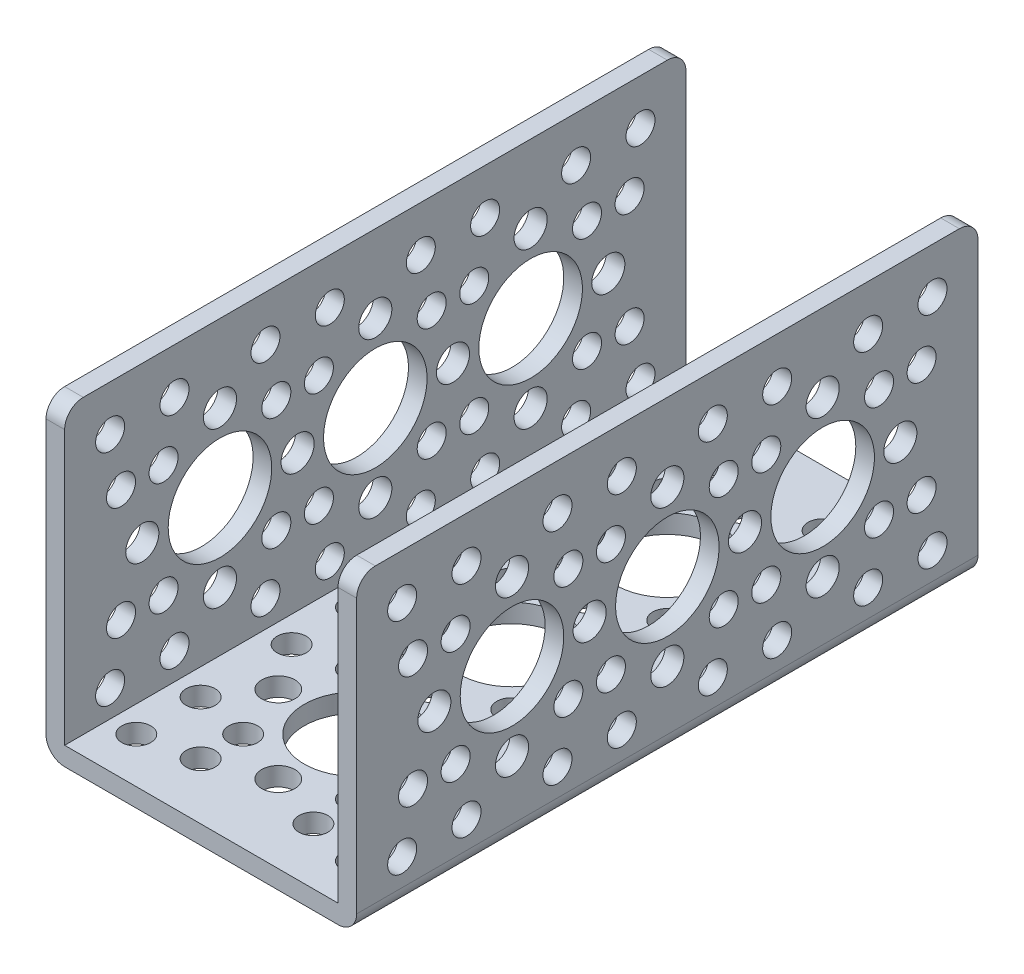
from build123d import *

# Parameters (mm, degrees)
EXTRUDE_THIN1_DEPTH = 76.2
SKETCH3_R           = 6.35
SKETCH3_R_2         = 2.032
SKETCH3_R_3         = 1.778
CUT_EXTRUDE1_DEPTH  = 2.286
SKETCH4_R           = 6.35
SKETCH4_R_2         = 2.032
SKETCH4_R_3         = 1.778
CUT_EXTRUDE2_DEPTH  = 39.1
FILLET1_R           = 2.286


with BuildPart() as part:
    # Sketch1 → Extrude-Thin1 (new body)
    with BuildSketch(Plane.XY):
        Polygon((0, 38.1), (0, 0), (38.1, 0), (38.1, 38.1), (35.814, 38.1), (35.814, 2.286), (2.286, 2.286), (2.286, 38.1), align=None)
    extrude(amount=EXTRUDE_THIN1_DEPTH)

    # Sketch3 → Cut-Extrude1 (cut)
    with BuildSketch(Plane.XZ):
        with Locations((19.05, 19.058384182)):
            Circle(SKETCH3_R)
        with Locations((19.05, 9.533384182)):
            Circle(SKETCH3_R_2)
        with Locations((9.525, 19.058384182)):
            Circle(SKETCH3_R_2)
        with Locations((19.05, 28.583384182)):
            Circle(SKETCH3_R_2)
        with Locations((28.575, 19.058384182)):
            Circle(SKETCH3_R_2)
        with Locations((12.135202787, 25.973181395)):
            Circle(SKETCH3_R_3)
        with Locations((5.579615818, 32.528768363)):
            Circle(SKETCH3_R_3)
        with Locations((25.964797213, 25.973181395)):
            Circle(SKETCH3_R_3)
        with Locations((32.520384182, 32.528768363)):
            Circle(SKETCH3_R_3)
        with Locations((25.964797213, 12.143586968)):
            Circle(SKETCH3_R_3)
        with Locations((32.520384182, 5.588)):
            Circle(SKETCH3_R_3)
        with Locations((12.135202787, 12.143586968)):
            Circle(SKETCH3_R_3)
        with Locations((5.579615818, 5.588)):
            Circle(SKETCH3_R_3)
        with Locations((12.135202787, 31.193586968)):
            Circle(SKETCH3_R_3)
        with Locations((25.964797213, 31.193586968)):
            Circle(SKETCH3_R_3)
        with Locations((25.964797213, 6.923181395)):
            Circle(SKETCH3_R_3)
        with Locations((12.135202787, 6.923181395)):
            Circle(SKETCH3_R_3)
        with Locations((32.520384182, 13.478768363)):
            Circle(SKETCH3_R_3)
        with Locations((5.579615818, 13.478768363)):
            Circle(SKETCH3_R_3)
        with Locations((5.579615818, 24.638)):
            Circle(SKETCH3_R_3)
        with Locations((32.520384182, 24.638)):
            Circle(SKETCH3_R_3)
        with Locations((18.971313238, 38.108384182)):
            Circle(SKETCH3_R)
        with Locations((9.446313238, 38.108384182)):
            Circle(SKETCH3_R_2)
        with Locations((28.496313238, 38.108384182)):
            Circle(SKETCH3_R_2)
        with Locations((18.971313238, 57.158384182)):
            Circle(SKETCH3_R)
        with Locations((18.971313238, 47.633384182)):
            Circle(SKETCH3_R_2)
        with Locations((9.446313238, 57.158384182)):
            Circle(SKETCH3_R_2)
        with Locations((18.971313238, 66.683384182)):
            Circle(SKETCH3_R_2)
        with Locations((28.496313238, 57.158384182)):
            Circle(SKETCH3_R_2)
        with Locations((12.056516025, 64.073181395)):
            Circle(SKETCH3_R_3)
        with Locations((5.500929056, 70.628768363)):
            Circle(SKETCH3_R_3)
        with Locations((25.886110451, 64.073181395)):
            Circle(SKETCH3_R_3)
        with Locations((32.441697419, 70.628768363)):
            Circle(SKETCH3_R_3)
        with Locations((25.886110451, 50.243586968)):
            Circle(SKETCH3_R_3)
        with Locations((32.441697419, 43.688)):
            Circle(SKETCH3_R_3)
        with Locations((12.056516025, 50.243586968)):
            Circle(SKETCH3_R_3)
        with Locations((5.500929056, 43.688)):
            Circle(SKETCH3_R_3)
        with Locations((12.056516025, 69.293586968)):
            Circle(SKETCH3_R_3)
        with Locations((25.886110451, 69.293586968)):
            Circle(SKETCH3_R_3)
        with Locations((25.886110451, 45.023181395)):
            Circle(SKETCH3_R_3)
        with Locations((12.056516025, 45.023181395)):
            Circle(SKETCH3_R_3)
        with Locations((32.441697419, 51.578768363)):
            Circle(SKETCH3_R_3)
        with Locations((5.500929056, 51.578768363)):
            Circle(SKETCH3_R_3)
        with Locations((5.500929056, 62.738)):
            Circle(SKETCH3_R_3)
        with Locations((32.441697419, 62.738)):
            Circle(SKETCH3_R_3)
    extrude(amount=-CUT_EXTRUDE1_DEPTH, mode=Mode.SUBTRACT)

    # Sketch4 → Cut-Extrude2 (cut, through all)
    with BuildSketch(Plane.ZY):
        with Locations((38.1, 19.05)):
            Circle(SKETCH4_R)
        with Locations((38.1, 9.525)):
            Circle(SKETCH4_R_2)
        with Locations((38.1, 28.575)):
            Circle(SKETCH4_R_2)
        with Locations((19.05, 19.05)):
            Circle(SKETCH4_R)
        with Locations((28.575, 19.05)):
            Circle(SKETCH4_R_2)
        with Locations((19.05, 9.525)):
            Circle(SKETCH4_R_2)
        with Locations((9.525, 19.05)):
            Circle(SKETCH4_R_2)
        with Locations((19.05, 28.575)):
            Circle(SKETCH4_R_2)
        with Locations((12.135202787, 12.135202787)):
            Circle(SKETCH4_R_3)
        with Locations((5.579615818, 5.579615818)):
            Circle(SKETCH4_R_3)
        with Locations((12.135202787, 25.964797213)):
            Circle(SKETCH4_R_3)
        with Locations((5.579615818, 32.520384182)):
            Circle(SKETCH4_R_3)
        with Locations((25.964797213, 25.964797213)):
            Circle(SKETCH4_R_3)
        with Locations((32.520384182, 32.520384182)):
            Circle(SKETCH4_R_3)
        with Locations((25.964797213, 12.135202787)):
            Circle(SKETCH4_R_3)
        with Locations((32.520384182, 5.579615818)):
            Circle(SKETCH4_R_3)
        with Locations((6.914797213, 12.135202787)):
            Circle(SKETCH4_R_3)
        with Locations((6.914797213, 25.964797213)):
            Circle(SKETCH4_R_3)
        with Locations((31.185202787, 25.964797213)):
            Circle(SKETCH4_R_3)
        with Locations((31.185202787, 12.135202787)):
            Circle(SKETCH4_R_3)
        with Locations((24.629615818, 32.520384182)):
            Circle(SKETCH4_R_3)
        with Locations((24.629615818, 5.579615818)):
            Circle(SKETCH4_R_3)
        with Locations((13.470384182, 5.579615818)):
            Circle(SKETCH4_R_3)
        with Locations((13.470384182, 32.520384182)):
            Circle(SKETCH4_R_3)
        with Locations((57.15, 19.05)):
            Circle(SKETCH4_R)
        with Locations((66.675, 19.05)):
            Circle(SKETCH4_R_2)
        with Locations((57.15, 9.525)):
            Circle(SKETCH4_R_2)
        with Locations((47.625, 19.05)):
            Circle(SKETCH4_R_2)
        with Locations((57.15, 28.575)):
            Circle(SKETCH4_R_2)
        with Locations((50.235202787, 12.135202787)):
            Circle(SKETCH4_R_3)
        with Locations((43.679615818, 5.579615818)):
            Circle(SKETCH4_R_3)
        with Locations((50.235202787, 25.964797213)):
            Circle(SKETCH4_R_3)
        with Locations((43.679615818, 32.520384182)):
            Circle(SKETCH4_R_3)
        with Locations((64.064797213, 25.964797213)):
            Circle(SKETCH4_R_3)
        with Locations((70.620384182, 32.520384182)):
            Circle(SKETCH4_R_3)
        with Locations((64.064797213, 12.135202787)):
            Circle(SKETCH4_R_3)
        with Locations((70.620384182, 5.579615818)):
            Circle(SKETCH4_R_3)
        with Locations((45.014797213, 12.135202787)):
            Circle(SKETCH4_R_3)
        with Locations((45.014797213, 25.964797213)):
            Circle(SKETCH4_R_3)
        with Locations((69.285202787, 25.964797213)):
            Circle(SKETCH4_R_3)
        with Locations((69.285202787, 12.135202787)):
            Circle(SKETCH4_R_3)
        with Locations((62.729615818, 32.520384182)):
            Circle(SKETCH4_R_3)
        with Locations((62.729615818, 5.579615818)):
            Circle(SKETCH4_R_3)
        with Locations((51.570384182, 5.579615818)):
            Circle(SKETCH4_R_3)
        with Locations((51.570384182, 32.520384182)):
            Circle(SKETCH4_R_3)
    extrude(amount=-CUT_EXTRUDE2_DEPTH, mode=Mode.SUBTRACT)

    # Fillet1
    fillet1_edges = [part.edges().sort_by_distance(p)[0] for p in [
        (38.1, 0, 38.1),
        (0, 0, 38.1),
        (36.957, 38.1, 76.2),
        (1.143, 38.1, 76.2),
        (36.957, 38.1, 0),
        (1.143, 38.1, 0),
    ]]
    fillet(fillet1_edges, radius=FILLET1_R)


solid = part.part
